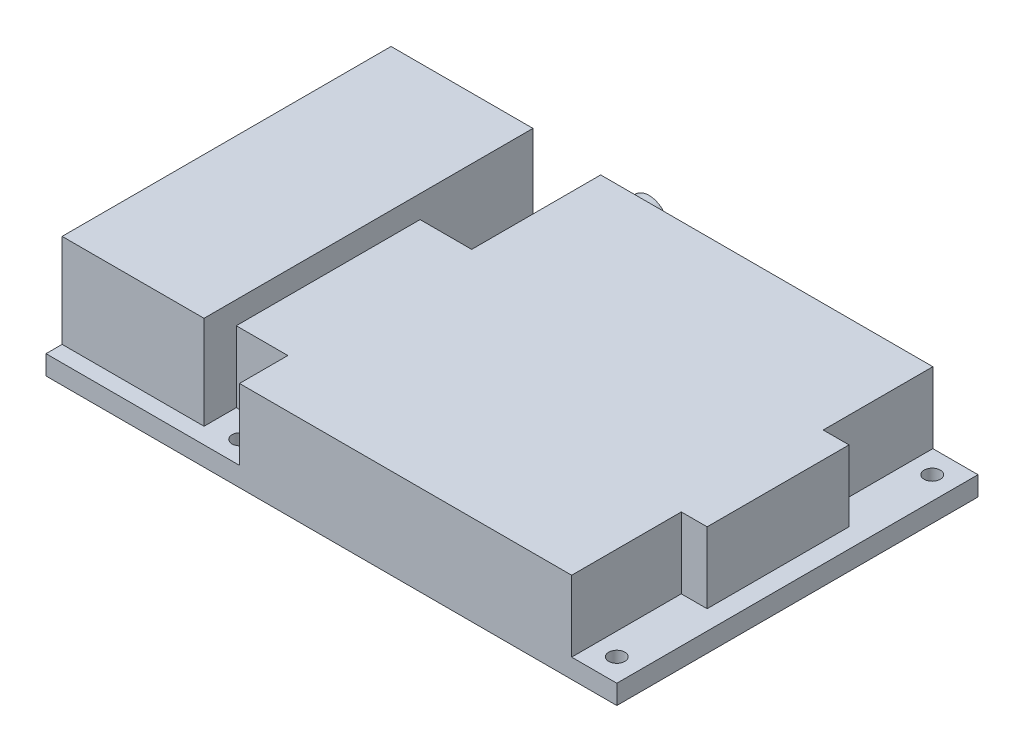
from build123d import *

# Parameters (mm, degrees)
SKETCH2_W               = 88.5
SKETCH2_H               = 56
BOSS_EXTRUDE1_DEPTH     = 3
SKETCH3_W               = 63.5
SKETCH3_H               = 56
BOSS_EXTRUDE2_DEPTH     = 11
SKETCH4_W               = 22
SKETCH4_H               = 51
BOSS_EXTRUDE3_DEPTH     = 14.5
SKETCH5_W               = 4
SKETCH5_H               = 17
SKETCH5_W_2             = 8
SKETCH5_H_2             = 7.5
SKETCH5_H_3             = 20
CUT_EXTRUDE1_DEPTH      = 4.5
CUT_EXTRUDE1_DEPTH_BACK = 11
SKETCH6_R               = 1.25
CUT_EXTRUDE2_DEPTH      = 18.5
CUT_EXTRUDE2_DEPTH_BACK = 1
SKETCH8_R               = 3
BOSS_EXTRUDE4_DEPTH     = 2.5


with BuildPart() as part:
    # Sketch2 → Boss-Extrude1 (new body)
    with BuildSketch(Plane(origin=(0, 0, 0), x_dir=(1, 0, 0), z_dir=(0, 1, 0))):
        with Locations((44.25, 28)):
            Rectangle(SKETCH2_W, SKETCH2_H)
    extrude(amount=BOSS_EXTRUDE1_DEPTH)

    # Sketch3 → Boss-Extrude2 (add)
    with BuildSketch(Plane(origin=(0, 3, 0), x_dir=(1, 0, 0), z_dir=(0, 1, 0))):
        with Locations((53.75, 28)):
            Rectangle(SKETCH3_W, SKETCH3_H)
    extrude(amount=BOSS_EXTRUDE2_DEPTH)

    # Sketch4 → Boss-Extrude3 (add)
    with BuildSketch(Plane(origin=(0, 3, 0), x_dir=(1, 0, 0), z_dir=(0, 1, 0))):
        with Locations((11, 28)):
            Rectangle(SKETCH4_W, SKETCH4_H)
    extrude(amount=BOSS_EXTRUDE3_DEPTH)

    # Sketch5 → Cut-Extrude1 (cut, two sides)
    with BuildSketch(Plane(origin=(0, 14, 0), x_dir=(1, 0, 0), z_dir=(0, 1, 0))) as cut_extrude1_sk:
        with Locations((83.5, 8.5)):
            Rectangle(SKETCH5_W, SKETCH5_H)
        with Locations((83.5, 47.5)):
            Rectangle(SKETCH5_W, SKETCH5_H)
        with Locations((26, 3.75)):
            Rectangle(SKETCH5_W_2, SKETCH5_H_2)
        with Locations((26, 46)):
            Rectangle(SKETCH5_W_2, SKETCH5_H_3)
    extrude(amount=CUT_EXTRUDE1_DEPTH, mode=Mode.SUBTRACT)
    extrude(cut_extrude1_sk.sketch, amount=-CUT_EXTRUDE1_DEPTH_BACK, mode=Mode.SUBTRACT)

    # Sketch6 → Cut-Extrude2 (cut, two sides)
    with BuildSketch(Plane(origin=(0, 0, 0), x_dir=(1, 0, 0), z_dir=(0, 1, 0))) as cut_extrude2_sk:
        with Locations((84.95, 52.45)):
            Circle(SKETCH6_R)
        with Locations((84.95, 3.55)):
            Circle(SKETCH6_R)
        with Locations((26.55, 3.55)):
            Circle(SKETCH6_R)
        with Locations((26.55, 52.45)):
            Circle(SKETCH6_R)
    extrude(amount=CUT_EXTRUDE2_DEPTH, mode=Mode.SUBTRACT)
    extrude(cut_extrude2_sk.sketch, amount=-CUT_EXTRUDE2_DEPTH_BACK, mode=Mode.SUBTRACT)

    # Sketch8 → Boss-Extrude4 (add)
    with BuildSketch(Plane(origin=(0, 0, -56), x_dir=(-1, 0, 0), z_dir=(0, 0, -1))):
        with Locations((-35, 9.5)):
            Circle(SKETCH8_R)
    extrude(amount=BOSS_EXTRUDE4_DEPTH)


solid = part.part
